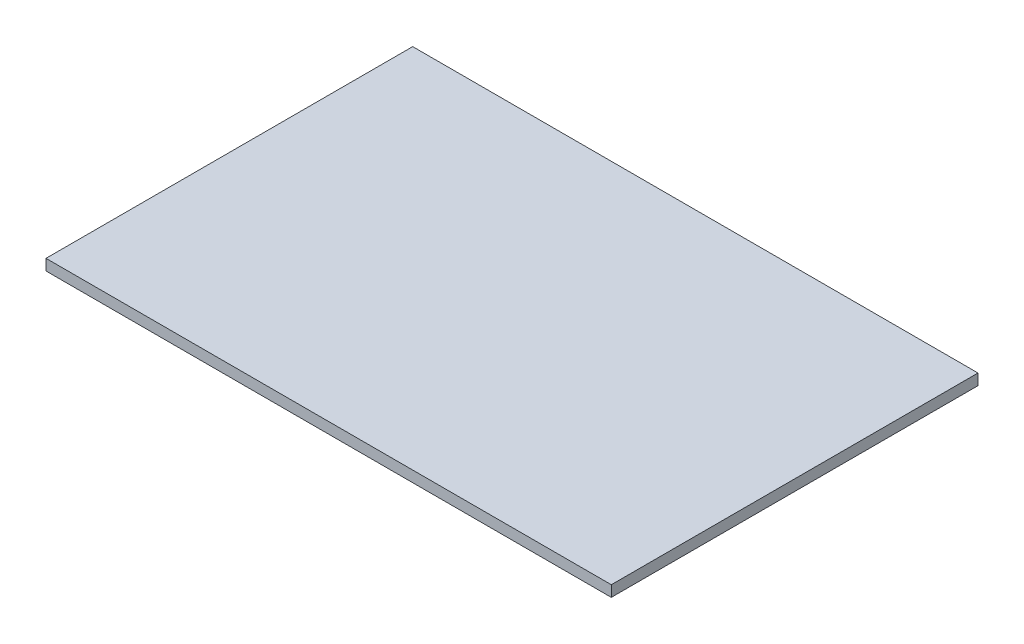
from build123d import *

# Parameters (mm, degrees)
SKETCH1_W           = 939.8
SKETCH1_H           = 609.6
BOSS_EXTRUDE1_DEPTH = 18.25625


with BuildPart() as part:
    # Sketch1 → Boss-Extrude1 (new body)
    with BuildSketch(Plane(origin=(0, 0, 0), x_dir=(1, 0, 0), z_dir=(0, 1, 0))):
        Rectangle(SKETCH1_W, SKETCH1_H)
    extrude(amount=BOSS_EXTRUDE1_DEPTH)


solid = part.part
